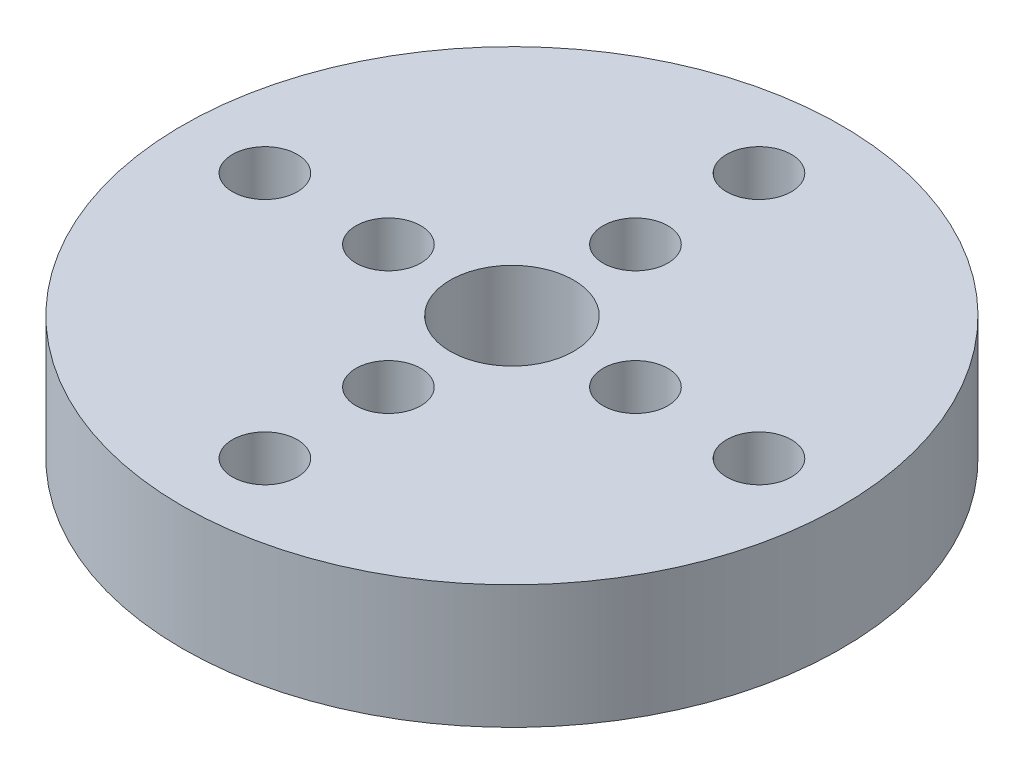
from build123d import *

# Parameters (mm, degrees)
SKETCH_1_R          = 21.345
EXTRUDE_1_DEPTH     = 8
SKETCH_2_R          = 4
CUT_EXTRUDE_1_DEPTH = 8
SKETCH_3_R          = 2.1
CUT_EXTRUDE_2_DEPTH = 8


with BuildPart() as part:
    # 스케치1 → 보스-돌출1 (new body)
    with BuildSketch(Plane(origin=(0, 0, 0), x_dir=(1, 0, 0), z_dir=(0, 1, 0))):
        Circle(SKETCH_1_R)
    extrude(amount=EXTRUDE_1_DEPTH)

    # 스케치2 → 컷-돌출1 (cut)
    with BuildSketch(Plane(origin=(0, 8, 0), x_dir=(1, 0, 0), z_dir=(0, 1, 0))):
        Circle(SKETCH_2_R)
    extrude(amount=-CUT_EXTRUDE_1_DEPTH, mode=Mode.SUBTRACT)

    # 스케치3 → 컷-돌출2 (cut)
    with BuildSketch(Plane(origin=(0, 8, 0), x_dir=(1, 0, 0), z_dir=(0, 1, 0))):
        with Locations((0, 8)):
            Circle(SKETCH_3_R)
        with Locations((0, 16)):
            Circle(SKETCH_3_R)
        with Locations((16, 0)):
            Circle(SKETCH_3_R)
        with Locations((8, 0)):
            Circle(SKETCH_3_R)
        with Locations((-8, 0)):
            Circle(SKETCH_3_R)
        with Locations((-16, 0)):
            Circle(SKETCH_3_R)
        with Locations((0, -8)):
            Circle(SKETCH_3_R)
        with Locations((0, -16)):
            Circle(SKETCH_3_R)
    extrude(amount=-CUT_EXTRUDE_2_DEPTH, mode=Mode.SUBTRACT)


solid = part.part
